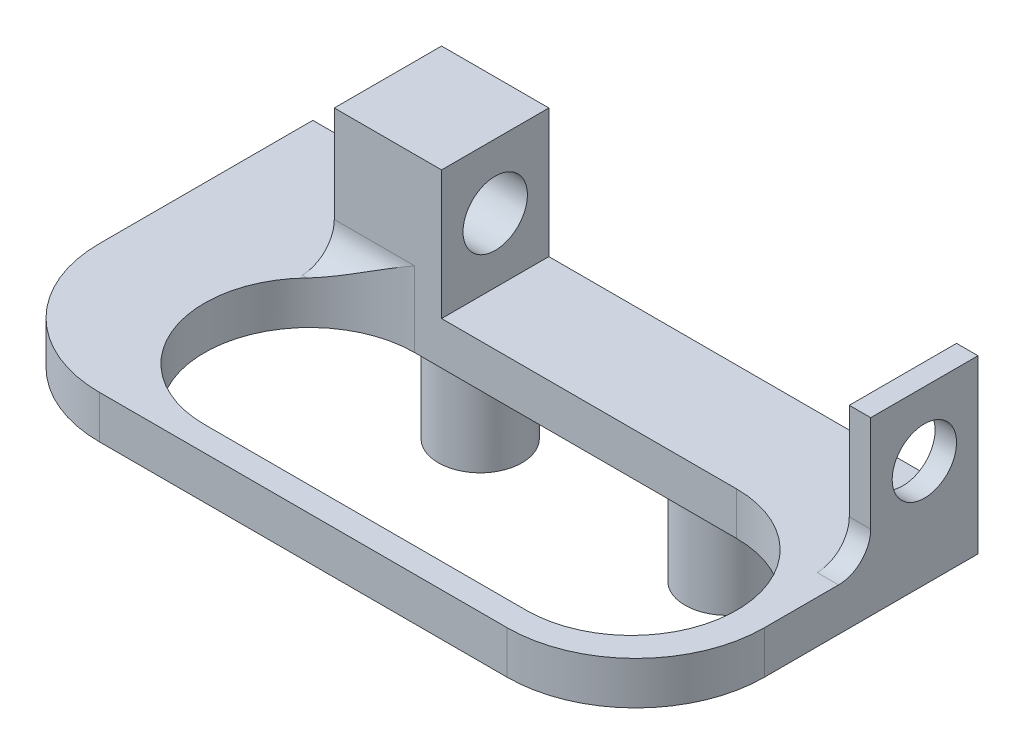
from build123d import *

# Parameters (mm, degrees)
SKETCH1_R             = 1.95
BOSS_EXTRUDE2_DEPTH   = 5
BOSS_EXTRUDE2_2_DEPTH = 5
SKETCH2_W             = 31
SKETCH2_H             = 15.95
BOSS_EXTRUDE4_DEPTH   = 2
CUT_EXTRUDE1_DEPTH    = 2
FILLET1_R             = 6
BOSS_EXTRUDE5_DEPTH   = 1
SKETCH6_W             = 1
SKETCH6_H             = 5
SKETCH6_W_2           = 5
BOSS_EXTRUDE6_DEPTH   = 6
SKETCH8_R             = 1.5
CUT_EXTRUDE3_DEPTH    = 26
FILLET5_R             = 1.5


with BuildPart() as part:
    # Sketch1 → Boss-Extrude2 (new body)
    with BuildSketch(Plane(origin=(0, 0, 0), x_dir=(1, 0, 0), z_dir=(0, 1, 0))):
        Circle(SKETCH1_R)
    extrude(amount=-BOSS_EXTRUDE2_DEPTH)



with BuildPart() as body_2:
    # Sketch1 → Boss-Extrude2 2 (new body)
    with BuildSketch(Plane(origin=(0, 0, 0), x_dir=(1, 0, 0), z_dir=(0, 1, 0))):
        with Locations((11.5, 0)):
            Circle(SKETCH1_R)
    extrude(amount=-BOSS_EXTRUDE2_2_DEPTH)


with BuildPart() as part_1:
    add(part.part)

    add(body_2.part)  # Boss-Extrude4 merges body 2
    # Sketch2 → Boss-Extrude4 (add)
    with BuildSketch(Plane(origin=(0, 0, 0), x_dir=(1, 0, 0), z_dir=(0, 1, 0))):
        with Locations((5.75, -6.025)):
            Rectangle(SKETCH2_W, SKETCH2_H)
    extrude(amount=BOSS_EXTRUDE4_DEPTH)

    # Sketch3 → Cut-Extrude1 (cut)
    with BuildSketch(Plane.XZ):
        with BuildLine():
            Line((0, 12.85), (15, 12.85))
            ThreePointArc((15, 12.85), (19.9, 7.95), (15, 3.05))
            Line((15, 3.05), (0, 3.05))
            ThreePointArc((0, 3.05), (-4.9, 7.95), (0, 12.85))
        make_face()
    extrude(amount=-CUT_EXTRUDE1_DEPTH, mode=Mode.SUBTRACT)

    # Fillet1
    fillet1_edges = [part_1.edges().sort_by_distance(p)[0] for p in [
        (-9.75, 1, 14),
        (21.25, 1, 14),
    ]]
    fillet(fillet1_edges, radius=FILLET1_R)

    # Sketch4 → Boss-Extrude5 (add)
    with BuildSketch(Plane.XZ):
        with BuildLine():
            Line((0, 1.95), (11.5, 1.95))
            ThreePointArc((11.5, 1.95), (13.45, 0), (11.5, -1.95))
            Line((11.5, -1.95), (0, -1.95))
            ThreePointArc((0, -1.95), (-1.95, 0), (0, 1.95))
        make_face()
    extrude(amount=BOSS_EXTRUDE5_DEPTH)

    # Sketch6 → Boss-Extrude6 (add)
    with BuildSketch(Plane(origin=(0, 2, 0), x_dir=(1, 0, 0), z_dir=(0, 1, 0))):
        with Locations((20.75, -0.55)):
            Rectangle(SKETCH6_W, SKETCH6_H)
        with Locations((-1.25, -0.55)):
            Rectangle(SKETCH6_W_2, SKETCH6_H)
    extrude(amount=BOSS_EXTRUDE6_DEPTH)

    # Sketch8 → Cut-Extrude3 (cut, through all)
    with BuildSketch(Plane.ZY.offset(3.75)):
        with Locations((0.55, 5)):
            Circle(SKETCH8_R)
    extrude(amount=-CUT_EXTRUDE3_DEPTH, mode=Mode.SUBTRACT)

    # Fillet5
    fillet5_edges = [part_1.edges().sort_by_distance(p)[0] for p in [
        (-1.875, 2, 3.05),
        (20.75, 2, 3.05),
    ]]
    fillet(fillet5_edges, radius=FILLET5_R)


solid = part_1.part
